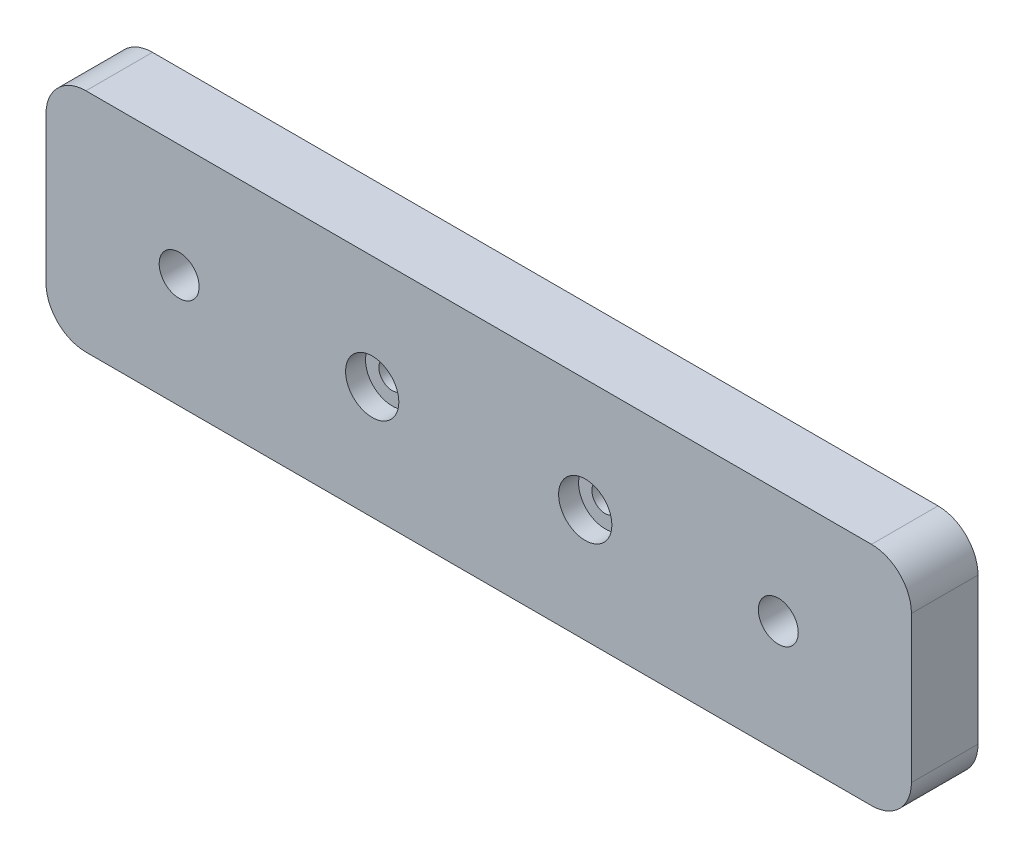
from build123d import *

# Parameters (mm, degrees)
SKETCH1_W           = 65
SKETCH1_H           = 17
SKETCH1_R           = 1.5
SKETCH1_R_2         = 1
BOSS_EXTRUDE1_DEPTH = 5
FILLET1_R           = 3
SKETCH3_R           = 2
CUT_EXTRUDE2_DEPTH  = 1.5
SKETCH4_R           = 3
CUT_EXTRUDE3_DEPTH  = 2


with BuildPart() as part:
    # Sketch1 → Boss-Extrude1 (new body)
    with BuildSketch(Plane.XY):
        with Locations((32.5, 8.5)):
            Rectangle(SKETCH1_W, SKETCH1_H)
        with Locations((55, 8.5)):
            Circle(SKETCH1_R, mode=Mode.SUBTRACT)
        with Locations((10, 8.5)):
            Circle(SKETCH1_R, mode=Mode.SUBTRACT)
        with Locations((24.5, 8.5)):
            Circle(SKETCH1_R_2, mode=Mode.SUBTRACT)
        with Locations((40.5, 8.5)):
            Circle(SKETCH1_R_2, mode=Mode.SUBTRACT)
    extrude(amount=BOSS_EXTRUDE1_DEPTH)

    # Fillet1
    fillet1_edges = [part.edges().sort_by_distance(p)[0] for p in [
        (0, 17, 2.5),
        (65, 17, 2.5),
        (65, 0, 2.5),
        (0, 0, 2.5),
    ]]
    fillet(fillet1_edges, radius=FILLET1_R)

    # Sketch3 → Cut-Extrude2 (cut)
    with BuildSketch(Plane.XY.offset(5)):
        with Locations((24.5, 8.5)):
            Circle(SKETCH3_R)
        with Locations((40.5, 8.5)):
            Circle(SKETCH3_R)
    extrude(amount=-CUT_EXTRUDE2_DEPTH, mode=Mode.SUBTRACT)

    # Sketch4 → Cut-Extrude3 (cut)
    with BuildSketch(Plane(origin=(0, 0, 0), x_dir=(-1, 0, 0), z_dir=(0, 0, -1))):
        with Locations((-55, 8.5)):
            Circle(SKETCH4_R)
        with Locations((-10, 8.5)):
            Circle(SKETCH4_R)
    extrude(amount=-CUT_EXTRUDE3_DEPTH, mode=Mode.SUBTRACT)


solid = part.part
